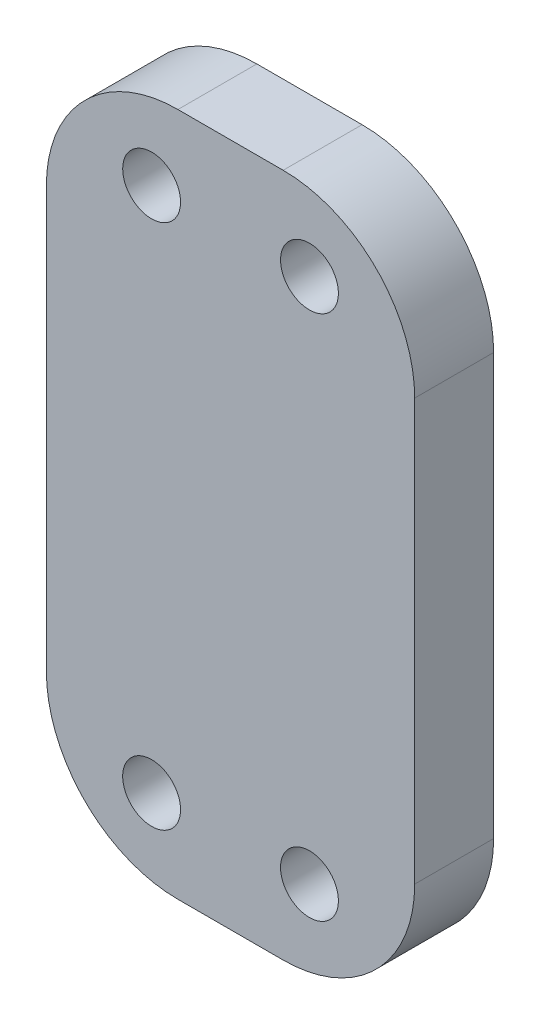
from build123d import *

# Parameters (mm, degrees)
SKETCH1_W           = 14
SKETCH1_H           = 26
SKETCH1_R           = 1.1
BOSS_EXTRUDE1_DEPTH = 3
FILLET1_R           = 5


with BuildPart() as part:
    # Sketch1 → Boss-Extrude1 (new body)
    with BuildSketch(Plane.XY):
        Rectangle(SKETCH1_W, SKETCH1_H)
        with Locations((3, 10)):
            Circle(SKETCH1_R, mode=Mode.SUBTRACT)
        with Locations((-3, 10)):
            Circle(SKETCH1_R, mode=Mode.SUBTRACT)
        with Locations((3, -10)):
            Circle(SKETCH1_R, mode=Mode.SUBTRACT)
        with Locations((-3, -10)):
            Circle(SKETCH1_R, mode=Mode.SUBTRACT)
    extrude(amount=BOSS_EXTRUDE1_DEPTH)

    # Fillet1
    fillet1_edges = [part.edges().sort_by_distance(p)[0] for p in [
        (-7, 13, 1.5),
        (7, 13, 1.5),
        (7, -13, 1.5),
        (-7, -13, 1.5),
    ]]
    fillet(fillet1_edges, radius=FILLET1_R)


solid = part.part
